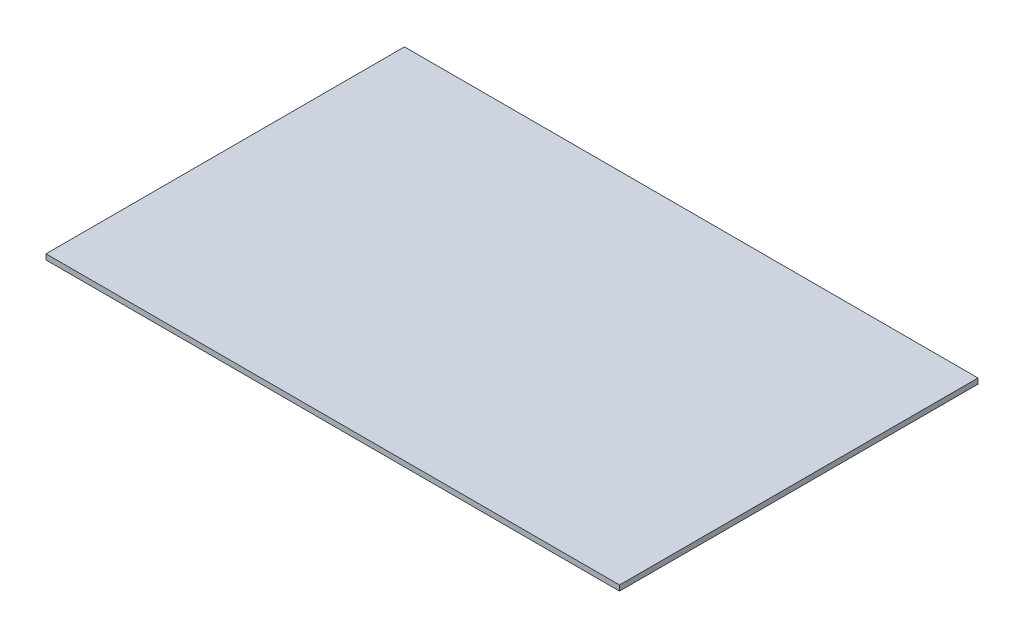
from build123d import *

# Parameters (mm, degrees)
SKETCH_1_W      = 160
SKETCH_1_H      = 100
EXTRUDE_1_DEPTH = 1.5


with BuildPart() as part:
    # Эскиз1 → Бобышка-Вытянуть1 (new body)
    with BuildSketch(Plane(origin=(0, 0, 0), x_dir=(1, 0, 0), z_dir=(0, 1, 0))):
        Rectangle(SKETCH_1_W, SKETCH_1_H)
    extrude(amount=EXTRUDE_1_DEPTH)


solid = part.part
